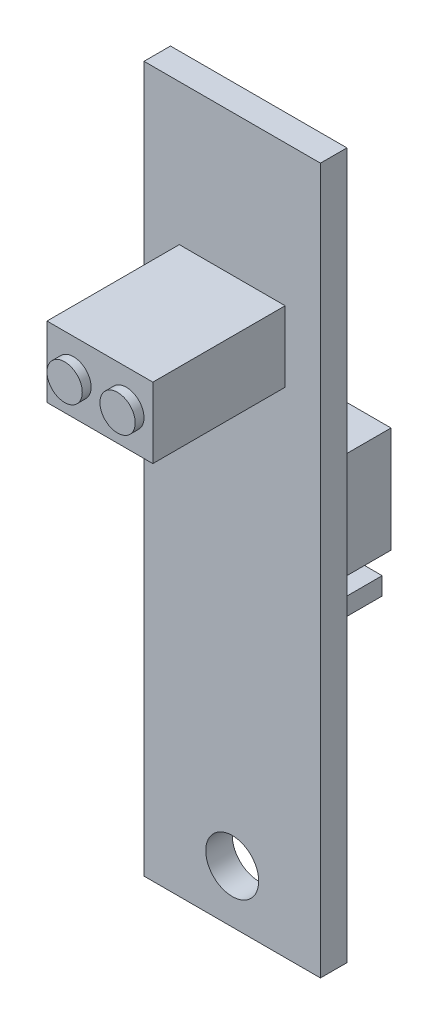
from build123d import *

# Parameters (mm, degrees)
SKETCH_2_W          = 10
SKETCH_2_H          = 40
SKETCH_2_R          = 1.5
EXTRUDE_1_DEPTH     = 1.5
SKETCH_3_W          = 6
SKETCH_3_H          = 4
EXTRUDE_2_DEPTH     = 8
SKETCH_3_3_W        = 6
SKETCH_3_3_H        = 6
EXTRUDE_3_DEPTH     = 6
SKETCH_3_4_W        = 6
SKETCH_3_4_H        = 2
EXTRUDE_4_DEPTH     = 2
SKETCH_4_W          = 1
SKETCH_4_H          = 1
EXTRUDE_5_DEPTH     = 4
SKETCH_5_W          = 6
SKETCH_5_H          = 4
SKETCH_5_R          = 1
CUT_EXTRUDE_1_DEPTH = 0.5


with BuildPart() as part:
    # 草圖2 → 填料-伸長1 (new body)
    with BuildSketch(Plane.XY):
        with Locations((5, 20)):
            Rectangle(SKETCH_2_W, SKETCH_2_H)
        with Locations((5, 3)):
            Circle(SKETCH_2_R, mode=Mode.SUBTRACT)
    extrude(amount=EXTRUDE_1_DEPTH)

    # 草圖3 → 填料-伸長2 (add)
    with BuildSketch(Plane.XY.offset(1.5)):
        with Locations((5, 30)):
            Rectangle(SKETCH_3_W, SKETCH_3_H)
    extrude(amount=EXTRUDE_2_DEPTH)

    # 草圖3<3> → 填料-伸長3 (add)
    with BuildSketch(Plane.XY.offset(1.5)):
        with Locations((5, 20)):
            Rectangle(SKETCH_3_3_W, SKETCH_3_3_H)
    extrude(amount=-EXTRUDE_3_DEPTH)

    # 草圖3<4> → 填料-伸長4 (add)
    with BuildSketch(Plane.XY.offset(1.5)):
        with Locations((5, 15)):
            Rectangle(SKETCH_3_4_W, SKETCH_3_4_H)
    extrude(amount=-EXTRUDE_4_DEPTH)

    # 草圖4 → 填料-伸長5 (add)
    with BuildSketch(Plane(origin=(0, 0, -0.5), x_dir=(-1, 0, 0), z_dir=(0, 0, -1))):
        with Locations((-5, 15)):
            Rectangle(SKETCH_4_W, SKETCH_4_H)
        with Locations((-7, 15)):
            Rectangle(SKETCH_4_W, SKETCH_4_H)
        with Locations((-3, 15)):
            Rectangle(SKETCH_4_W, SKETCH_4_H)
    extrude(amount=EXTRUDE_5_DEPTH)

    # 草圖5 → 除料-伸長1 (cut)
    with BuildSketch(Plane.XY.offset(9.5)):
        with Locations((5, 30)):
            Rectangle(SKETCH_5_W, SKETCH_5_H)
        with Locations((3.5, 30)):
            Circle(SKETCH_5_R, mode=Mode.SUBTRACT)
        with Locations((6.5, 30)):
            Circle(SKETCH_5_R, mode=Mode.SUBTRACT)
    extrude(amount=-CUT_EXTRUDE_1_DEPTH, mode=Mode.SUBTRACT)


solid = part.part
